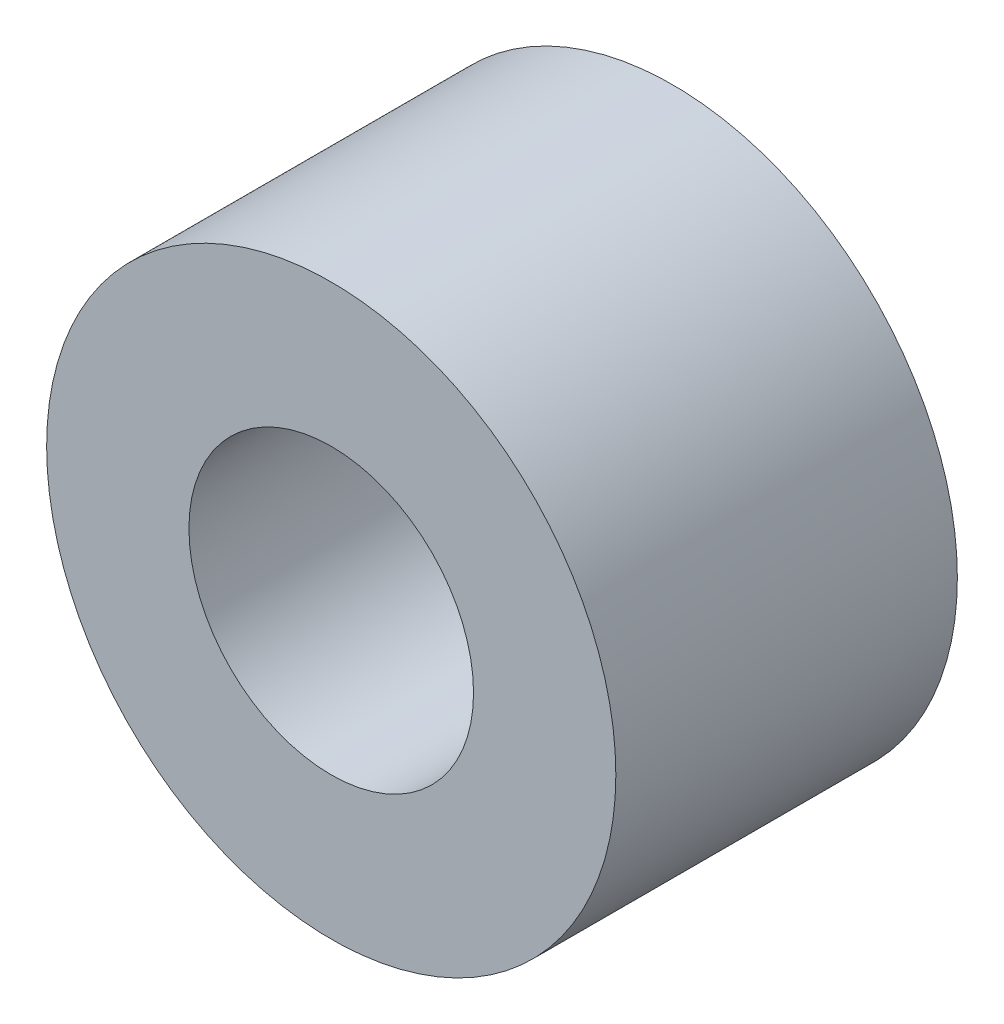
from build123d import *

# Parameters (mm, degrees)
SKETCH1_R           = 5
SKETCH1_R_2         = 2.5
BOSS_EXTRUDE1_DEPTH = 6


with BuildPart() as part:
    # Sketch1 → Boss-Extrude1 (new body)
    with BuildSketch(Plane.XY):
        Circle(SKETCH1_R)
        Circle(SKETCH1_R_2, mode=Mode.SUBTRACT)
    extrude(amount=BOSS_EXTRUDE1_DEPTH)


solid = part.part
